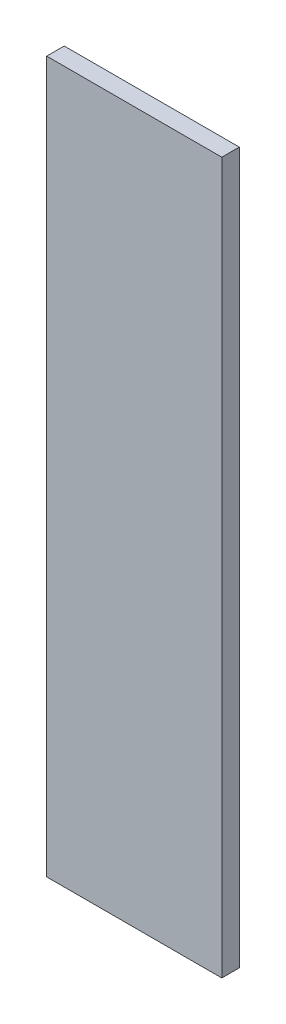
from build123d import *

# Parameters (mm, degrees)
SKETCH1_W           = 250
SKETCH1_H           = 1015
BOSS_EXTRUDE1_DEPTH = 25


with BuildPart() as part:
    # Sketch1 → Boss-Extrude1 (new body)
    with BuildSketch(Plane.XY):
        with Locations((125, 507.5)):
            Rectangle(SKETCH1_W, SKETCH1_H)
    extrude(amount=BOSS_EXTRUDE1_DEPTH)


solid = part.part
